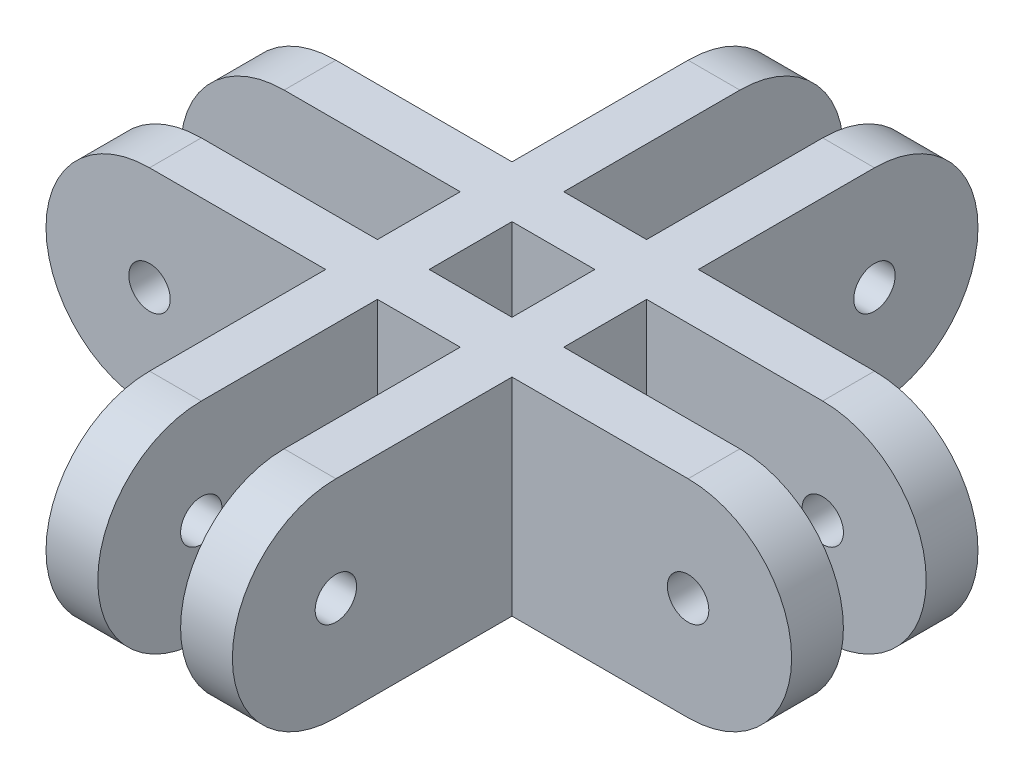
from build123d import *

# Parameters (mm, degrees)
CROQUIS1_R              = 2
SALIENTE_EXTRUIR1_DEPTH = 5
CROQUIS3_R              = 2
SALIENTE_EXTRUIR2_DEPTH = 5
CROQUIS5_R              = 2
SALIENTE_EXTRUIR3_DEPTH = 5
CROQUIS6_R              = 2
SALIENTE_EXTRUIR4_DEPTH = 5


with BuildPart() as part:
    # Croquis1 → Saliente-Extruir1 (new body)
    with BuildSketch(Plane.XY):
        with BuildLine():
            Line((-52.02, -10), (-26.01, -10))
            Line((-26.01, -10), (-26.01, 10))
            Line((-26.01, 10), (-52.02, 10))
            ThreePointArc((-52.02, 10), (-62.02, 0), (-52.02, -10))
        make_face()
        with Locations((-52.02, 0)):
            Circle(CROQUIS1_R, mode=Mode.SUBTRACT)
        with BuildLine():
            Line((-26.01, 10), (-26.01, -10))
            Line((-26.01, -10), (0, -10))
            ThreePointArc((0, -10), (10, 0), (0, 10))
            Line((0, 10), (-26.01, 10))
        make_face()
        Circle(CROQUIS1_R, mode=Mode.SUBTRACT)
    extrude(amount=SALIENTE_EXTRUIR1_DEPTH)



with BuildPart() as body_2:
    # Croquis3 → Saliente-Extruir2 (new body)
    with BuildSketch(Plane.XY.offset(13)):
        with BuildLine():
            Line((-52.02, 10), (0, 10))
            ThreePointArc((0, 10), (10, 0), (0, -10))
            Line((0, -10), (-52.02, -10))
            ThreePointArc((-52.02, -10), (-62.02, 0), (-52.02, 10))
        make_face()
        with Locations((-52.02, 0)):
            Circle(CROQUIS3_R, mode=Mode.SUBTRACT)
        Circle(CROQUIS3_R, mode=Mode.SUBTRACT)
    extrude(amount=SALIENTE_EXTRUIR2_DEPTH)


with BuildPart() as part_1:
    add(part.part)

    add(body_2.part)  # Saliente-Extruir3 merges body 2
    # Croquis5 → Saliente-Extruir3 (add)
    with BuildSketch(Plane(origin=(-17.01, 10, 0), x_dir=(0, 0, -1), z_dir=(1, 0, 0))):
        with BuildLine():
            Line((-35.01, -20), (17.01, -20))
            ThreePointArc((17.01, -20), (27.01, -10), (17.01, 0))
            Line((17.01, 0), (-35.01, 0))
            ThreePointArc((-35.01, 0), (-45.01, -10), (-35.01, -20))
        make_face()
        with Locations((17.01, -10)):
            Circle(CROQUIS5_R, mode=Mode.SUBTRACT)
        with Locations((-35.01, -10)):
            Circle(CROQUIS5_R, mode=Mode.SUBTRACT)
    extrude(amount=-SALIENTE_EXTRUIR3_DEPTH)

    # Croquis6 → Saliente-Extruir4 (add)
    with BuildSketch(Plane(origin=(-35.01, 10, 0), x_dir=(0, 0, -1), z_dir=(1, 0, 0))):
        with BuildLine():
            Line((17.01, 0), (-9, 0))
            Line((-9, 0), (-9, -20))
            Line((-9, -20), (17.01, -20))
            ThreePointArc((17.01, -20), (27.01, -10), (17.01, 0))
        make_face()
        with Locations((17.01, -10)):
            Circle(CROQUIS6_R, mode=Mode.SUBTRACT)
        with BuildLine():
            Line((-9, -20), (-9, 0))
            Line((-9, 0), (-35.01, 0))
            ThreePointArc((-35.01, 0), (-45.01, -10), (-35.01, -20))
            Line((-35.01, -20), (-9, -20))
        make_face()
        with Locations((-35.01, -10)):
            Circle(CROQUIS6_R, mode=Mode.SUBTRACT)
    extrude(amount=SALIENTE_EXTRUIR4_DEPTH)


solid = part_1.part
